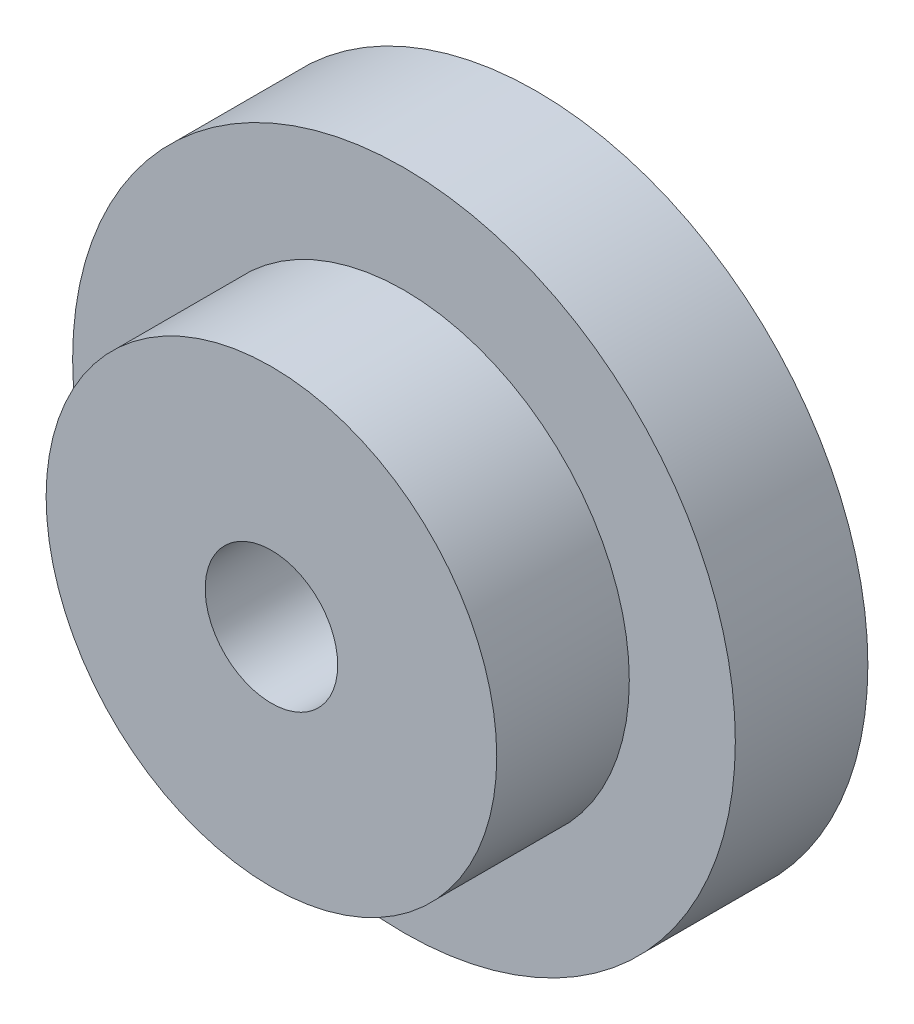
from build123d import *

# Parameters (mm, degrees)
SKETCH_1_R      = 2.5
SKETCH_1_R_2    = 0.5
EXTRUDE_1_DEPTH = 1
SKETCH_2_R      = 1.7
SKETCH_2_R_2    = 0.5
EXTRUDE_2_DEPTH = 1


with BuildPart() as part:
    # 草图1 → 凸台-拉伸1 (new body)
    with BuildSketch(Plane.XY):
        Circle(SKETCH_1_R)
        Circle(SKETCH_1_R_2, mode=Mode.SUBTRACT)
    extrude(amount=EXTRUDE_1_DEPTH)

    # 草图2 → 凸台-拉伸2 (add)
    with BuildSketch(Plane.XY.offset(1)):
        Circle(SKETCH_2_R)
        Circle(SKETCH_2_R_2, mode=Mode.SUBTRACT)
    extrude(amount=EXTRUDE_2_DEPTH)


solid = part.part
